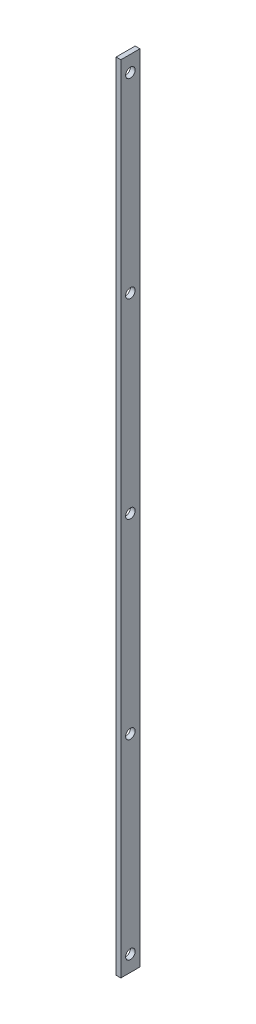
from build123d import *

# Parameters (mm, degrees)
SKETCH1_W           = 12
SKETCH1_H           = 500
BOSS_EXTRUDE1_DEPTH = 3
SKETCH3_R           = 3
CUT_EXTRUDE1_DEPTH  = 3


with BuildPart() as part:
    # Sketch1 → Boss-Extrude1 (new body)
    with BuildSketch(Plane(origin=(0, 0, 0), x_dir=(0, 0, -1), z_dir=(1, 0, 0))):
        Rectangle(SKETCH1_W, SKETCH1_H)
    extrude(amount=BOSS_EXTRUDE1_DEPTH)

    # Sketch3 → Cut-Extrude1 (cut)
    with BuildSketch(Plane.ZY):
        with Locations((0, 240)):
            Circle(SKETCH3_R)
        with Locations((0, 120)):
            Circle(SKETCH3_R)
        Circle(SKETCH3_R)
        with Locations((0, -120)):
            Circle(SKETCH3_R)
        with Locations((0, -240)):
            Circle(SKETCH3_R)
    extrude(amount=-CUT_EXTRUDE1_DEPTH, mode=Mode.SUBTRACT)


solid = part.part
